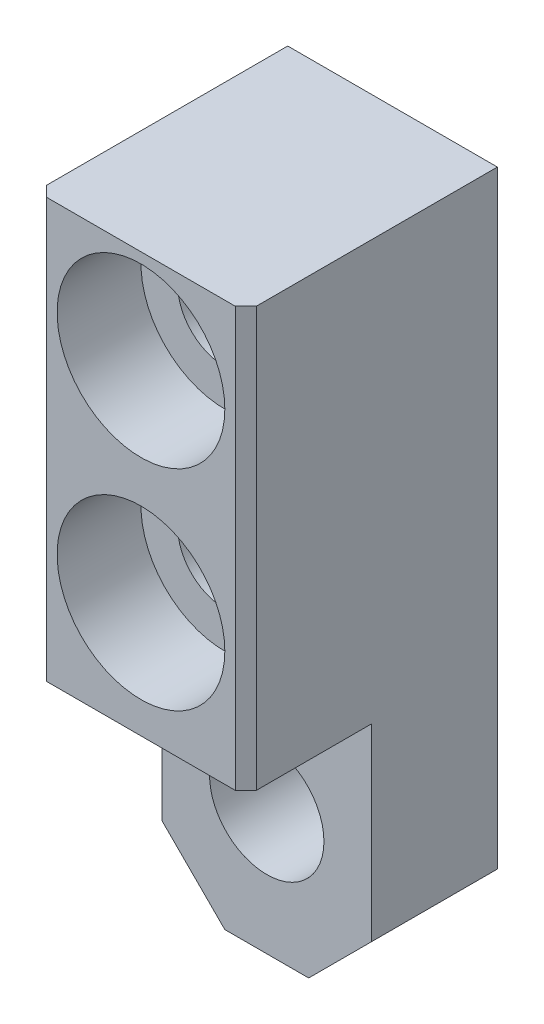
from build123d import *

# Parameters (mm, degrees)
SKETCH1_W           = 10
SKETCH1_H           = 32
BOSS_EXTRUDE1_DEPTH = 6
SKETCH2_W           = 10
SKETCH2_H           = 20
BOSS_EXTRUDE2_DEPTH = 6
SKETCH3_R           = 2.25
CUT_EXTRUDE1_DEPTH  = 13
SKETCH4_R           = 4
CUT_EXTRUDE2_DEPTH  = 4
CHAMFER1_SIZE       = 3
CHAMFER2_SIZE       = 0.5
SKETCH5_R           = 2.727238267
CUT_EXTRUDE3_DEPTH  = 7


with BuildPart() as part:
    # Sketch1 → Boss-Extrude1 (new body)
    with BuildSketch(Plane.XY):
        with Locations((5, -16)):
            Rectangle(SKETCH1_W, SKETCH1_H)
    extrude(amount=BOSS_EXTRUDE1_DEPTH)

    # Sketch2 → Boss-Extrude2 (add)
    with BuildSketch(Plane.XY.offset(6)):
        with Locations((5, -10)):
            Rectangle(SKETCH2_W, SKETCH2_H)
    extrude(amount=BOSS_EXTRUDE2_DEPTH)

    # Sketch3 → Cut-Extrude1 (cut, through all)
    with BuildSketch(Plane.XY.offset(12)):
        with Locations((5, -4.5)):
            Circle(SKETCH3_R)
        with Locations((5, -14.5)):
            Circle(SKETCH3_R)
    extrude(amount=-CUT_EXTRUDE1_DEPTH, mode=Mode.SUBTRACT)

    # Sketch4 → Cut-Extrude2 (cut)
    with BuildSketch(Plane.XY.offset(12)):
        with Locations((5, -4.5)):
            Circle(SKETCH4_R)
        with Locations((5, -14.5)):
            Circle(SKETCH4_R)
    extrude(amount=-CUT_EXTRUDE2_DEPTH, mode=Mode.SUBTRACT)

    # Chamfer1
    chamfer1_edges = [part.edges().sort_by_distance(p)[0] for p in [
        (10, -32, 3),
        (0, -32, 3),
    ]]
    chamfer(chamfer1_edges, length=CHAMFER1_SIZE)

    # Chamfer2
    chamfer2_edges = [part.edges().sort_by_distance(p)[0] for p in [
        (0, -10, 12),
        (10, -10, 12),
    ]]
    chamfer(chamfer2_edges, length=CHAMFER2_SIZE)

    # Sketch5 → Cut-Extrude3 (cut, through all)
    with BuildSketch(Plane.XY.offset(6)):
        with Locations((5, -26)):
            Circle(SKETCH5_R)
    extrude(amount=-CUT_EXTRUDE3_DEPTH, mode=Mode.SUBTRACT)


solid = part.part
